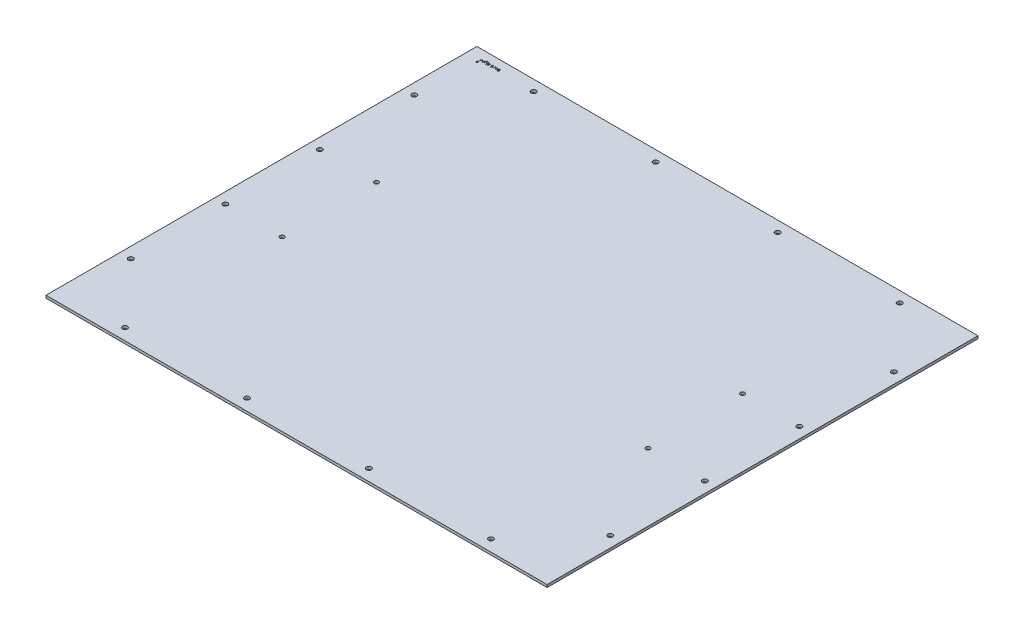
from build123d import *

# Parameters (mm, degrees)
SKETCH1_W                = 584.2
SKETCH1_H                = 502.3866
TOPPLATE_DEPTH           = 3.0734
SKETCH2_R                = 2.8956
FRONT_REARTOPHOLES_DEPTH = 4.0734
LPATTERN1_COUNT          = 4
LPATTERN1_PITCH          = 142.24
SKETCH3_R                = 2.8956
CUT_EXTRUDE2_DEPTH       = 4.0734
LPATTERN2_COUNT          = 4
LPATTERN2_PITCH          = 110.202133333
F_10_CLEARANCE_HOLE1_D   = 5.1054
SKETCH6_W                = 0.284935897
SKETCH6_H                = 2.320192308
CUT_EXTRUDE3_DEPTH       = 1.27


with BuildPart() as part:
    # Sketch1 → TopPlate (new body)
    with BuildSketch(Plane(origin=(0, 0, 0), x_dir=(1, 0, 0), z_dir=(0, 1, 0))):
        Rectangle(SKETCH1_W, SKETCH1_H)
    extrude(amount=TOPPLATE_DEPTH)

    # Sketch2 → Front/RearTopHoles (cut, through all)
    with BuildSketch(Plane(origin=(0, 3.0734, 0), x_dir=(1, 0, 0), z_dir=(0, 1, 0))):
        with Locations((-213.36, 238.5949)):
            Circle(SKETCH2_R)
        with Locations((-213.36, -237.8583)):
            Circle(SKETCH2_R)
    front_reartopholes = extrude(amount=-FRONT_REARTOPHOLES_DEPTH, mode=Mode.SUBTRACT)

    # LPattern1: Front/RearTopHoles ×4
    with Locations(*[(i * LPATTERN1_PITCH, 0, 0) for i in range(1, LPATTERN1_COUNT)]):
        add(front_reartopholes, mode=Mode.SUBTRACT)

    # Sketch3 → Cut-Extrude2 (cut, through all)
    with BuildSketch(Plane(origin=(0, 3.0734, 0), x_dir=(1, 0, 0), z_dir=(0, 1, 0))):
        with Locations((-279.5016, 165.6715)):
            Circle(SKETCH3_R)
        with Locations((279.5016, 165.6715)):
            Circle(SKETCH3_R)
    cut_extrude2 = extrude(amount=-CUT_EXTRUDE2_DEPTH, mode=Mode.SUBTRACT)

    # LPattern2: Cut-Extrude2 ×4
    with Locations(*[(0, 0, i * LPATTERN2_PITCH) for i in range(1, LPATTERN2_COUNT)]):
        add(cut_extrude2, mode=Mode.SUBTRACT)

    # #10 Clearance Hole1 (through all)
    with Locations(Plane(origin=(0, 3.0734, 0), x_dir=(1, 0, 0), z_dir=(0, 1, 0))):
        with Locations((-213.36, 55.469366667), (-213.36, -54.732766667), (213.36, -54.732766667), (213.36, 55.469366667)):
            Hole(F_10_CLEARANCE_HOLE1_D / 2)

    # Sketch6 → Cut-Extrude3 (cut)
    with BuildSketch(Plane(origin=(0, 3.0734, 0), x_dir=(1, 0, 0), z_dir=(0, 1, 0))):
        Polygon((-276.606, 234.501752747), (-275.59, 235.771752747), (-276.098, 235.771752747), (-276.098, 237.041752747), (-277.114, 237.041752747), (-277.114, 235.771752747), (-277.622, 235.771752747), align=None)
        Polygon((-275.751192308, 238.234089744), (-276.036128205, 238.234089744), (-276.036128205, 239.170307692), (-276.443179487, 239.170307692), (-276.443179487, 239.45524359), (-276.036128205, 239.45524359), (-276.036128205, 241.4905), (-275.751192308, 241.4905), (-275.751192308, 239.45524359), (-275.344141026, 239.45524359), (-275.344141026, 239.170307692), (-275.751192308, 239.170307692), align=None)
        with BuildLine():
            Line((-272.779717949, 238.234089744), (-273.064653846, 238.234089744))
            Line((-273.064653846, 238.234089744), (-273.064653846, 239.608523838))
            add(Edge.make_bspline(
                [(-273.064653846, 239.608523838), (-273.095288957, 239.570346385), (-273.154842441, 239.496130876), (-273.254397625, 239.398250964), (-273.358134855, 239.314880555), (-273.466934482, 239.246800624), (-273.580334104, 239.193987133), (-273.698612372, 239.157038512), (-273.821467744, 239.133998173), (-273.905156662, 239.131078123), (-273.947446314, 239.129602564)],
                knots=[0, 0, 0, 0, 0.000146744, 0.000285264, 0.000417869, 0.000545289, 0.000669358, 0.000792061, 0.000916189, 0.001042986, 0.001042986, 0.001042986, 0.001042986], degree=3))
            add(Edge.make_bspline(
                [(-273.947446314, 239.129602564), (-273.99040245, 239.131096275), (-274.074520115, 239.134021292), (-274.196554238, 239.159794398), (-274.311327974, 239.200580783), (-274.417308171, 239.257903038), (-274.51285836, 239.329075871), (-274.595732695, 239.412549345), (-274.665255082, 239.507224035), (-274.71177071, 239.5954719), (-274.742257141, 239.673949775), (-274.761528408, 239.7412988), (-274.777876587, 239.81633759), (-274.792117817, 239.899037579), (-274.801609985, 239.989792673), (-274.809234113, 240.088194368), (-274.814655629, 240.194236739), (-274.814865725, 240.267642968), (-274.814974359, 240.305599159)],
                knots=[0, 0, 0, 0, 0.000128741, 0.000252104, 0.000372411, 0.000493068, 0.000612131, 0.000728612, 0.000844628, 0.000963265, 0.001026692, 0.001096933, 0.001173163, 0.001257021, 0.001348539, 0.001446782, 0.001553119, 0.001666973, 0.001666973, 0.001666973, 0.001666973], degree=3))
            Line((-274.814974359, 240.305599159), (-274.814974359, 241.4905))
            Line((-274.814974359, 241.4905), (-274.530038462, 241.4905))
            Line((-274.530038462, 241.4905), (-274.530038462, 240.39909375))
            add(Edge.make_bspline(
                [(-274.530038462, 240.39909375), (-274.52986652, 240.367504573), (-274.529537624, 240.307079855), (-274.528437062, 240.220569698), (-274.526036138, 240.14231524), (-274.522012923, 240.072154038), (-274.517964628, 240.010181175), (-274.512225203, 239.956295425), (-274.505597355, 239.91083483), (-274.499638148, 239.883471229), (-274.496965545, 239.871199119)],
                knots=[0, 0, 0, 0, 9.4769e-05, 0.000181277, 0.000259548, 0.000329614, 0.000392103, 0.000445834, 0.000492158, 0.000529829, 0.000529829, 0.000529829, 0.000529829], degree=3))
            add(Edge.make_bspline(
                [(-274.496965545, 239.871199119), (-274.486650236, 239.835164317), (-274.466871505, 239.766070641), (-274.41998111, 239.672384203), (-274.362778171, 239.591782233), (-274.291875741, 239.526554072), (-274.209629226, 239.475158281), (-274.115257802, 239.4401423), (-274.009967367, 239.417812227), (-273.935909524, 239.415662226), (-273.897200921, 239.414538462)],
                knots=[0, 0, 0, 0, 0.000112235, 0.000215201, 0.000312651, 0.000407163, 0.00050229, 0.000601745, 0.000707647, 0.000823614, 0.000823614, 0.000823614, 0.000823614], degree=3))
            add(Edge.make_bspline(
                [(-273.897200921, 239.414538462), (-273.874277404, 239.414963891), (-273.828912354, 239.415805804), (-273.761678637, 239.424472437), (-273.696256264, 239.438160215), (-273.632820828, 239.458378282), (-273.571242928, 239.482959628), (-273.511272258, 239.513125858), (-273.453729552, 239.549600076), (-273.397872102, 239.590651447), (-273.345874308, 239.636065114), (-273.29749967, 239.684006601), (-273.254375428, 239.735055575), (-273.215306109, 239.788395801), (-273.181580081, 239.844758182), (-273.152140503, 239.903599394), (-273.127161691, 239.964996766), (-273.114749535, 240.007609858), (-273.108539062, 240.02893149)],
                knots=[0, 0, 0, 0, 6.8737e-05, 0.000136029, 0.000203016, 0.000268997, 0.00033549, 0.000401764, 0.000470059, 0.000539641, 0.000609525, 0.000676984, 0.000743763, 0.00080979, 0.000875126, 0.000940547, 0.00100704, 0.001073628, 0.001073628, 0.001073628, 0.001073628], degree=3))
            add(Edge.make_bspline(
                [(-273.108539062, 240.02893149), (-273.104965439, 240.044371924), (-273.097178074, 240.078018531), (-273.08872819, 240.133512382), (-273.081164617, 240.197997876), (-273.074770576, 240.271377207), (-273.070848919, 240.353919262), (-273.066623229, 240.445060775), (-273.06505023, 240.545372651), (-273.064789923, 240.615127861), (-273.064653846, 240.651592748)],
                knots=[0, 0, 0, 0, 4.7531e-05, 0.000103577, 0.000168266, 0.000242318, 0.000324485, 0.000416151, 0.000516024, 0.000625421, 0.000625421, 0.000625421, 0.000625421], degree=3))
            Line((-273.064653846, 240.651592748), (-273.064653846, 241.4905))
            Line((-273.064653846, 241.4905), (-272.779717949, 241.4905))
            Line((-272.779717949, 241.4905), (-272.779717949, 238.234089744))
        make_face()
        with BuildLine():
            Line((-271.8435, 239.170307692), (-272.128435897, 239.170307692))
            Line((-272.128435897, 239.170307692), (-272.128435897, 241.011578726))
            add(Edge.make_bspline(
                [(-272.128435897, 241.011578726), (-272.12818458, 241.050801401), (-272.127699478, 241.126510612), (-272.124206096, 241.235983051), (-272.116839482, 241.337098715), (-272.108485893, 241.430318764), (-272.096469229, 241.515211106), (-272.081794953, 241.592029056), (-272.065252586, 241.660846331), (-272.050719961, 241.703232436), (-272.043845553, 241.723282452)],
                knots=[0, 0, 0, 0, 0.00011767, 0.000227132, 0.0003285, 0.000421785, 0.000507864, 0.000585575, 0.000656379, 0.000719936, 0.000719936, 0.000719936, 0.000719936], degree=3))
            add(Edge.make_bspline(
                [(-272.043845553, 241.723282452), (-272.033696249, 241.749345441), (-272.013701098, 241.800692153), (-271.976235724, 241.873463997), (-271.934344658, 241.942040388), (-271.886342636, 242.0056571), (-271.83338637, 242.065242755), (-271.774817784, 242.119937838), (-271.710779765, 242.169673775), (-271.641845981, 242.21492206), (-271.568506921, 242.255357007), (-271.491164154, 242.290601015), (-271.410011572, 242.319746935), (-271.325408027, 242.343779291), (-271.237316212, 242.363153814), (-271.145454597, 242.376084095), (-271.050130374, 242.384789849), (-270.985320336, 242.385601191), (-270.952439303, 242.386012821)],
                knots=[0, 0, 0, 0, 8.3858e-05, 0.000165209, 0.000245167, 0.00032467, 0.00040395, 0.000484048, 0.000564709, 0.000646913, 0.000731175, 0.000815711, 0.00090162, 0.000989596, 0.001079416, 0.001171971, 0.001267732, 0.001366347, 0.001366347, 0.001366347, 0.001366347], degree=3))
            add(Edge.make_bspline(
                [(-270.952439303, 242.386012821), (-270.90447824, 242.385140136), (-270.810822493, 242.383436007), (-270.674004238, 242.367091364), (-270.544657436, 242.340891053), (-270.423652145, 242.303172693), (-270.311909172, 242.256728639), (-270.209791061, 242.203946576), (-270.119001866, 242.142785218), (-270.037232791, 242.0734154), (-269.963448258, 241.990890778), (-269.894025893, 241.893648398), (-269.827205256, 241.780194164), (-269.788045081, 241.696925164), (-269.767538462, 241.653320513)],
                knots=[0, 0, 0, 0, 0.00014383, 0.000280863, 0.000412709, 0.000539245, 0.000660431, 0.000775365, 0.0008835, 0.000988151, 0.001096222, 0.001214668, 0.001346108, 0.001490606, 0.001490606, 0.001490606, 0.001490606], degree=3))
            Line((-269.767538462, 241.653320513), (-270.052474359, 241.653320513))
            add(Edge.make_bspline(
                [(-270.052474359, 241.653320513), (-270.075401181, 241.689690608), (-270.120220295, 241.760789664), (-270.203755387, 241.852938639), (-270.295975421, 241.930967298), (-270.398837112, 241.994278604), (-270.513057864, 242.043017864), (-270.639376644, 242.076871614), (-270.778139147, 242.097352938), (-270.874770736, 242.099801738), (-270.925090545, 242.101076923)],
                knots=[0, 0, 0, 0, 0.000128773, 0.000251735, 0.000371362, 0.000490154, 0.000612668, 0.000742586, 0.000881465, 0.001032363, 0.001032363, 0.001032363, 0.001032363], degree=3))
            add(Edge.make_bspline(
                [(-270.925090545, 242.101076923), (-270.974775422, 242.099790902), (-271.070562891, 242.097311581), (-271.20845158, 242.076771655), (-271.334609236, 242.043101585), (-271.447422374, 241.994555846), (-271.545815237, 241.935771451), (-271.631421221, 241.871385539), (-271.700260177, 241.797651596), (-271.746752525, 241.729856808), (-271.77562316, 241.669412722), (-271.794025821, 241.61738927), (-271.808867227, 241.558750354), (-271.821607536, 241.493356365), (-271.831702776, 241.421182106), (-271.838326273, 241.341981473), (-271.843027303, 241.25629015), (-271.843338791, 241.196878996), (-271.8435, 241.16613101)],
                knots=[0, 0, 0, 0, 0.000148992, 0.000287243, 0.00041716, 0.000539674, 0.000654314, 0.000760413, 0.000859854, 0.000955639, 0.001005707, 0.001060427, 0.001120899, 0.001187008, 0.001260225, 0.0013394, 0.001425378, 0.001517609, 0.001517609, 0.001517609, 0.001517609], degree=3))
            Line((-271.8435, 241.16613101), (-271.8435, 241.045923678))
            add(Edge.make_bspline(
                [(-271.8435, 241.045923678), (-271.814569532, 241.080328344), (-271.757217475, 241.148532507), (-271.658438924, 241.238064123), (-271.549866918, 241.314241385), (-271.433036156, 241.377605615), (-271.309687811, 241.427808387), (-271.182002694, 241.464184676), (-271.050339266, 241.486747874), (-270.961221094, 241.489240421), (-270.916186298, 241.4905)],
                knots=[0, 0, 0, 0, 0.000134741, 0.000267112, 0.000398573, 0.000531766, 0.000664992, 0.000797261, 0.000929425, 0.001064443, 0.001064443, 0.001064443, 0.001064443], degree=3))
            add(Edge.make_bspline(
                [(-270.916186298, 241.4905), (-270.889674897, 241.489940414), (-270.836985562, 241.488828282), (-270.758487063, 241.48206311), (-270.681501426, 241.468889036), (-270.605538248, 241.452019574), (-270.531128225, 241.429406531), (-270.457379793, 241.402866048), (-270.38536394, 241.370267322), (-270.314713264, 241.333565607), (-270.247089783, 241.292328762), (-270.182706743, 241.247775307), (-270.121957835, 241.200001608), (-270.065414273, 241.148567792), (-270.013123282, 241.093557625), (-269.964495723, 241.035490185), (-269.919971489, 240.973908019), (-269.880127551, 240.908787337), (-269.843726172, 240.841715809), (-269.812559987, 240.772372177), (-269.786688047, 240.701195133), (-269.763886912, 240.6290745), (-269.747740892, 240.55469513), (-269.735394701, 240.478938573), (-269.728467691, 240.401342651), (-269.727380427, 240.34907289), (-269.726833333, 240.322771635)],
                knots=[0, 0, 0, 0, 7.9543e-05, 0.000158085, 0.000236088, 0.000313697, 0.00039137, 0.000469237, 0.000548668, 0.000628323, 0.000707949, 0.000786107, 0.000863089, 0.000939628, 0.001015205, 0.001090612, 0.001166693, 0.001242943, 0.00131949, 0.001395499, 0.001470759, 0.001546605, 0.001622214, 0.001698859, 0.001776768, 0.001855675, 0.001855675, 0.001855675, 0.001855675], degree=3))
            add(Edge.make_bspline(
                [(-269.726833333, 240.322771635), (-269.727303962, 240.296461557), (-269.728243396, 240.243943305), (-269.736368104, 240.166040304), (-269.747932416, 240.089171622), (-269.766331604, 240.014171274), (-269.788163501, 239.939956522), (-269.816478574, 239.867735626), (-269.849101148, 239.796552813), (-269.886387195, 239.72703231), (-269.928124933, 239.659813714), (-269.974066934, 239.59627373), (-270.023252779, 239.535883841), (-270.076672319, 239.479418604), (-270.134009781, 239.426454791), (-270.195431838, 239.377457165), (-270.260255323, 239.331540083), (-270.328702263, 239.289711312), (-270.399710776, 239.252715774), (-270.471478379, 239.218958689), (-270.544955332, 239.192167008), (-270.618771855, 239.168560344), (-270.694227919, 239.151836987), (-270.77039834, 239.138935382), (-270.84754389, 239.131075242), (-270.899208302, 239.13009409), (-270.925090545, 239.129602564)],
                knots=[0, 0, 0, 0, 7.8907e-05, 0.000157509, 0.000234782, 0.000311916, 0.000388979, 0.000466698, 0.000544391, 0.000623781, 0.0007032, 0.000781572, 0.000858855, 0.000936691, 0.001014559, 0.00109283, 0.001172238, 0.001252739, 0.001333252, 0.001412367, 0.001490455, 0.001567704, 0.001644694, 0.001722069, 0.001799404, 0.00187704, 0.00187704, 0.00187704, 0.00187704], degree=3))
            add(Edge.make_bspline(
                [(-270.925090545, 239.129602564), (-270.967775914, 239.130814084), (-271.051856641, 239.13320051), (-271.175840296, 239.152506785), (-271.295608346, 239.182597742), (-271.411774325, 239.22634062), (-271.525047299, 239.285536822), (-271.634745544, 239.364511684), (-271.742747017, 239.461705246), (-271.809060471, 239.536988825), (-271.8435, 239.576086939)],
                knots=[0, 0, 0, 0, 0.000127998, 0.000252127, 0.000375534, 0.000497914, 0.000623661, 0.000757781, 0.000902347, 0.00105855, 0.00105855, 0.00105855, 0.00105855], degree=3))
            Line((-271.8435, 239.576086939), (-271.8435, 239.170307692))
        make_face()
        with BuildLine():
            add(Edge.make_bspline(
                [(-270.947987179, 239.414538462), (-270.906324102, 239.415959755), (-270.823840042, 239.418773616), (-270.702890132, 239.442632797), (-270.586393338, 239.480395931), (-270.475504221, 239.532961353), (-270.372755286, 239.599381768), (-270.28086539, 239.678451332), (-270.20059951, 239.768785992), (-270.133524905, 239.870078155), (-270.079438352, 239.979026265), (-270.040630891, 240.093669245), (-270.015842236, 240.212527338), (-270.013135685, 240.293393231), (-270.011769231, 240.334219952)],
                knots=[0, 0, 0, 0, 0.000124893, 0.000247261, 0.000368342, 0.000491529, 0.000614314, 0.00073428, 0.000854125, 0.000975665, 0.001097689, 0.001217965, 0.001337959, 0.001460312, 0.001460312, 0.001460312, 0.001460312], degree=3))
            add(Edge.make_bspline(
                [(-270.011769231, 240.334219952), (-270.01242994, 240.365001466), (-270.013729363, 240.425539702), (-270.026145185, 240.514394939), (-270.046434926, 240.59916618), (-270.07454538, 240.679716085), (-270.110232087, 240.756363269), (-270.15530564, 240.828211546), (-270.207481931, 240.896554451), (-270.26728107, 240.959917012), (-270.333086668, 241.017707641), (-270.404413334, 241.068222957), (-270.480874622, 241.110106127), (-270.561247668, 241.145767369), (-270.647234371, 241.172001358), (-270.737545276, 241.191983431), (-270.832786176, 241.203424212), (-270.897712186, 241.204841499), (-270.930814704, 241.205564103)],
                knots=[0, 0, 0, 0, 9.2301e-05, 0.00018153, 0.000268534, 0.000353418, 0.000437066, 0.000521609, 0.000607348, 0.000694638, 0.000782531, 0.000869702, 0.00095625, 0.00104369, 0.001133005, 0.001225446, 0.001320902, 0.001420194, 0.001420194, 0.001420194, 0.001420194], degree=3))
            add(Edge.make_bspline(
                [(-270.930814704, 241.205564103), (-270.964346113, 241.204867772), (-271.029916429, 241.203506104), (-271.125684347, 241.191800786), (-271.216428342, 241.172912283), (-271.302065155, 241.146094381), (-271.382918321, 241.111875417), (-271.458078847, 241.068571294), (-271.529161001, 241.019255701), (-271.593885242, 240.961729277), (-271.652440982, 240.898343518), (-271.703365192, 240.829323404), (-271.74710102, 240.756000943), (-271.781910316, 240.677441311), (-271.810623886, 240.59468262), (-271.828726051, 240.506329395), (-271.841708964, 240.413682037), (-271.842893913, 240.350169433), (-271.8435, 240.317683494)],
                knots=[0, 0, 0, 0, 0.000100563, 0.00019665, 0.000288958, 0.000378273, 0.000465461, 0.000551765, 0.00063805, 0.000724567, 0.000810991, 0.000896473, 0.000981445, 0.00106656, 0.00115385, 0.00124367, 0.001336681, 0.001434067, 0.001434067, 0.001434067, 0.001434067], degree=3))
            add(Edge.make_bspline(
                [(-271.8435, 240.317683494), (-271.84228264, 240.275395339), (-271.839904347, 240.192779144), (-271.817531089, 240.072382543), (-271.781237896, 239.959063042), (-271.730868708, 239.853110797), (-271.667460113, 239.756000859), (-271.590338308, 239.670194953), (-271.5029189, 239.593316589), (-271.403052269, 239.530133743), (-271.296014202, 239.478434889), (-271.183571689, 239.441407847), (-271.066954016, 239.419102752), (-270.98794091, 239.416071329), (-270.947987179, 239.414538462)],
                knots=[0, 0, 0, 0, 0.000126761, 0.000247646, 0.000365914, 0.00048284, 0.00059856, 0.000712542, 0.000827958, 0.00094669, 0.001065886, 0.001183746, 0.001300879, 0.001420694, 0.001420694, 0.001420694, 0.001420694], degree=3))
        make_face(mode=Mode.SUBTRACT)
        with BuildLine():
            add(Edge.make_bspline(
                [(-269.013221554, 238.193384615), (-269.03090001, 238.194208369), (-269.065517822, 238.195821435), (-269.115627934, 238.209524526), (-269.16121077, 238.233106406), (-269.202245007, 238.263716262), (-269.236260502, 238.301194976), (-269.260651423, 238.343779081), (-269.276222513, 238.390138508), (-269.278113917, 238.422440769), (-269.279076923, 238.43888742)],
                knots=[0, 0, 0, 0, 5.2977e-05, 0.000103739, 0.000154369, 0.000206141, 0.000256583, 0.000305021, 0.000352489, 0.000401726, 0.000401726, 0.000401726, 0.000401726], degree=3))
            add(Edge.make_bspline(
                [(-269.279076923, 238.43888742), (-269.278092374, 238.454907167), (-269.276146037, 238.486576312), (-269.260662934, 238.532131925), (-269.236056013, 238.574123055), (-269.202267647, 238.611528496), (-269.161204791, 238.642120668), (-269.115629515, 238.66570722), (-269.065517406, 238.679409077), (-269.03089987, 238.681022314), (-269.013221554, 238.681846154)],
                knots=[0, 0, 0, 0, 4.7972e-05, 9.4835e-05, 0.000142722, 0.000193165, 0.000244937, 0.000295567, 0.000346329, 0.000399306, 0.000399306, 0.000399306, 0.000399306], degree=3))
            add(Edge.make_bspline(
                [(-269.013221554, 238.681846154), (-268.995746279, 238.681048773), (-268.961732938, 238.679496774), (-268.912544204, 238.665543289), (-268.867694811, 238.642171959), (-268.827331639, 238.611105142), (-268.79287337, 238.574371777), (-268.768357242, 238.532100207), (-268.752832742, 238.486584388), (-268.750891984, 238.45490988), (-268.749910256, 238.43888742)],
                knots=[0, 0, 0, 0, 5.2343e-05, 0.000101879, 0.000151943, 0.000203209, 0.000254078, 0.000301966, 0.000348828, 0.0003968, 0.0003968, 0.0003968, 0.0003968], degree=3))
            add(Edge.make_bspline(
                [(-268.749910256, 238.43888742), (-268.750870335, 238.422437953), (-268.752755991, 238.390130162), (-268.768369291, 238.343811342), (-268.792666358, 238.300944133), (-268.827353903, 238.264139309), (-268.867688983, 238.233055228), (-268.912545722, 238.209688412), (-268.961732535, 238.195733747), (-268.995746142, 238.194181913), (-269.013221554, 238.193384615)],
                knots=[0, 0, 0, 0, 4.9237e-05, 9.6705e-05, 0.000145142, 0.000196012, 0.000247277, 0.000297341, 0.000346877, 0.00039922, 0.00039922, 0.00039922, 0.00039922], degree=3))
        make_face()
        with Locations((-269.01449359, 240.330403846)):
            Rectangle(SKETCH6_W, SKETCH6_H)
        with BuildLine():
            Line((-266.307602564, 238.3155), (-266.942984175, 238.3155))
            add(Edge.make_bspline(
                [(-266.942984175, 238.3155), (-266.985385056, 238.315641139), (-267.066799444, 238.315912141), (-267.183433768, 238.317423226), (-267.289412634, 238.321754248), (-267.384680631, 238.32548132), (-267.469236011, 238.332277582), (-267.543338053, 238.338773311), (-267.606645465, 238.347276561), (-267.644968487, 238.355173623), (-267.662320112, 238.358749199)],
                knots=[0, 0, 0, 0, 0.000127205, 0.000244248, 0.000349896, 0.000445402, 0.000530231, 0.00060434, 0.000668562, 0.000721699, 0.000721699, 0.000721699, 0.000721699], degree=3))
            add(Edge.make_bspline(
                [(-267.662320112, 238.358749199), (-267.685549369, 238.364487843), (-267.731512341, 238.375842711), (-267.797682798, 238.399854569), (-267.860763154, 238.427596928), (-267.920522408, 238.460430236), (-267.9769449, 238.497800062), (-268.030024945, 238.539856633), (-268.079050844, 238.586960289), (-268.125766864, 238.637159811), (-268.166558873, 238.692640823), (-268.203282502, 238.750587813), (-268.234110731, 238.812116403), (-268.258369106, 238.876916258), (-268.278705613, 238.944351724), (-268.292373644, 239.015089154), (-268.300886333, 239.088898406), (-268.301727387, 239.139119001), (-268.302153846, 239.164583534)],
                knots=[0, 0, 0, 0, 7.1738e-05, 0.000141945, 0.000210849, 0.000278309, 0.000346223, 0.000413668, 0.000481152, 0.000550033, 0.000619105, 0.000687399, 0.000755663, 0.000825118, 0.000894749, 0.00096672, 0.00104096, 0.001117325, 0.001117325, 0.001117325, 0.001117325], degree=3))
            add(Edge.make_bspline(
                [(-268.302153846, 239.164583534), (-268.30082129, 239.206888284), (-268.298221127, 239.28943581), (-268.273977157, 239.409233216), (-268.234267366, 239.520986009), (-268.179539017, 239.624538669), (-268.109876865, 239.717927231), (-268.026158798, 239.799676017), (-267.928812361, 239.868716591), (-267.837763743, 239.91608451), (-267.757298009, 239.946563059), (-267.690859166, 239.968115533), (-267.618330587, 239.984486719), (-267.540752805, 239.99936584), (-267.457526603, 240.010719804), (-267.368819576, 240.018783277), (-267.274409863, 240.023968151), (-267.209694508, 240.024725683), (-267.176402644, 240.025115385)],
                knots=[0, 0, 0, 0, 0.000126797, 0.000247415, 0.000364897, 0.000481551, 0.000597433, 0.000713022, 0.000831097, 0.00095427, 0.001019706, 0.001089102, 0.001163613, 0.001242574, 0.001326045, 0.001415471, 0.001509739, 0.001609612, 0.001609612, 0.001609612, 0.001609612], degree=3))
            Line((-267.176402644, 240.025115385), (-268.342858974, 241.4905))
            Line((-268.342858974, 241.4905), (-267.990505208, 241.4905))
            Line((-267.990505208, 241.4905), (-266.824048878, 240.025115385))
            Line((-266.824048878, 240.025115385), (-266.592538462, 240.025115385))
            Line((-266.592538462, 240.025115385), (-266.592538462, 241.4905))
            Line((-266.592538462, 241.4905), (-266.307602564, 241.4905))
            Line((-266.307602564, 241.4905), (-266.307602564, 238.3155))
        make_face()
        with BuildLine():
            Line((-266.592538462, 238.641141026), (-266.592538462, 239.699474359))
            Line((-266.592538462, 239.699474359), (-267.173858574, 239.703926482))
            add(Edge.make_bspline(
                [(-267.173858574, 239.703926482), (-267.201000327, 239.703938497), (-267.253608774, 239.703961784), (-267.329718617, 239.700338765), (-267.400584876, 239.696217644), (-267.465935604, 239.689912535), (-267.525802933, 239.681791581), (-267.58014732, 239.671617517), (-267.629088859, 239.65981444), (-267.685987255, 239.641359418), (-267.750254088, 239.613381499), (-267.818657485, 239.569999305), (-267.878474298, 239.517534935), (-267.928205373, 239.45678401), (-267.968149429, 239.389702433), (-267.995894134, 239.317808361), (-268.014177733, 239.242234554), (-268.016192859, 239.190344063), (-268.017217949, 239.163947516)],
                knots=[0, 0, 0, 0, 8.1413e-05, 0.000157801, 0.000228539, 0.000294357, 0.000354712, 0.000409723, 0.000460165, 0.000505621, 0.000589056, 0.00066969, 0.000747651, 0.000826724, 0.000904279, 0.000980813, 0.001057183, 0.001136257, 0.001136257, 0.001136257, 0.001136257], degree=3))
            add(Edge.make_bspline(
                [(-268.017217949, 239.163947516), (-268.016140955, 239.138409559), (-268.014006748, 239.087802648), (-267.996185248, 239.013882177), (-267.967085562, 238.943593511), (-267.927255561, 238.877903868), (-267.877682853, 238.818716571), (-267.819941812, 238.768229723), (-267.755391215, 238.726286689), (-267.695548611, 238.698612572), (-267.641669192, 238.682329079), (-267.595104151, 238.67050891), (-267.542030906, 238.662230598), (-267.483074123, 238.654616763), (-267.417974809, 238.648169012), (-267.346693292, 238.643889312), (-267.26928054, 238.641331329), (-267.215625838, 238.641205936), (-267.187850962, 238.641141026)],
                knots=[0, 0, 0, 0, 7.6536e-05, 0.000151667, 0.000226669, 0.000304005, 0.000381204, 0.00045737, 0.000533227, 0.000611498, 0.000654145, 0.000701964, 0.0007555, 0.00081514, 0.000880324, 0.000951697, 0.001029333, 0.001112654, 0.001112654, 0.001112654, 0.001112654], degree=3))
            Line((-267.187850962, 238.641141026), (-266.592538462, 238.641141026))
        make_face(mode=Mode.SUBTRACT)
        Polygon((-262.806961538, 238.234089744), (-263.091897436, 238.234089744), (-263.091897436, 240.116701923), (-264.147686699, 239.170307692), (-264.557282051, 239.170307692), (-263.332312099, 240.269346154), (-264.679397436, 241.4905), (-264.270438101, 241.4905), (-263.091897436, 240.421354367), (-263.091897436, 241.4905), (-262.806961538, 241.4905), align=None)
        with BuildLine():
            Line((-262.237089744, 239.673397636), (-261.998583133, 239.821589744))
            add(Edge.make_bspline(
                [(-261.998583133, 239.821589744), (-261.972431786, 239.789085519), (-261.9209573, 239.72510647), (-261.831547298, 239.64258677), (-261.736214838, 239.571423144), (-261.633162437, 239.514204555), (-261.523292996, 239.469036372), (-261.406380165, 239.437645079), (-261.282460017, 239.4179139), (-261.197489687, 239.415682043), (-261.153951723, 239.414538462)],
                knots=[0, 0, 0, 0, 0.000125005, 0.00024605, 0.000363844, 0.000481156, 0.000598675, 0.000719332, 0.000843558, 0.000974097, 0.000974097, 0.000974097, 0.000974097], degree=3))
            add(Edge.make_bspline(
                [(-261.153951723, 239.414538462), (-261.11915471, 239.415497226), (-261.05062294, 239.417385488), (-260.950014629, 239.429187036), (-260.854184043, 239.450636711), (-260.762518032, 239.478884263), (-260.675714028, 239.516797438), (-260.593528846, 239.56265657), (-260.515687598, 239.616657062), (-260.443426861, 239.678409888), (-260.377572077, 239.746236817), (-260.319329021, 239.817864949), (-260.270717442, 239.89379579), (-260.230195809, 239.972588209), (-260.19970807, 240.055597704), (-260.177288136, 240.141815831), (-260.163622283, 240.231809924), (-260.16196647, 240.293043705), (-260.161128205, 240.32404367)],
                knots=[0, 0, 0, 0, 0.000104402, 0.000205617, 0.000303301, 0.000398648, 0.000492936, 0.000586896, 0.000680581, 0.000776679, 0.000871582, 0.000963859, 0.001053128, 0.00114159, 0.001229132, 0.001317833, 0.001408501, 0.001501466, 0.001501466, 0.001501466, 0.001501466], degree=3))
            add(Edge.make_bspline(
                [(-260.161128205, 240.32404367), (-260.162763055, 240.364651715), (-260.166019092, 240.445528448), (-260.190893213, 240.564678621), (-260.232248688, 240.679882941), (-260.289215405, 240.789796934), (-260.360354232, 240.891832705), (-260.44332621, 240.984103519), (-260.540014864, 241.062753641), (-260.647571015, 241.128578406), (-260.764055698, 241.181707496), (-260.888544673, 241.21919749), (-261.019978048, 241.241952777), (-261.109974323, 241.244811622), (-261.155859776, 241.246269231)],
                knots=[0, 0, 0, 0, 0.00012176, 0.000242503, 0.000363409, 0.000488003, 0.000612742, 0.000735658, 0.000859034, 0.000985243, 0.001113046, 0.001242014, 0.001374284, 0.001511876, 0.001511876, 0.001511876, 0.001511876], degree=3))
            add(Edge.make_bspline(
                [(-261.155859776, 241.246269231), (-261.19791055, 241.245090401), (-261.280551481, 241.242773688), (-261.401353232, 241.223243843), (-261.516360723, 241.191272832), (-261.625569865, 241.146688893), (-261.728781101, 241.08906036), (-261.825327567, 241.017977398), (-261.917130368, 240.935484911), (-261.971102625, 240.871696466), (-261.998583133, 240.839217949)],
                knots=[0, 0, 0, 0, 0.000126092, 0.000247804, 0.000366009, 0.000483528, 0.00060084, 0.00071966, 0.000842576, 0.00097008, 0.00097008, 0.00097008, 0.00097008], degree=3))
            Line((-261.998583133, 240.839217949), (-262.237089744, 240.995678285))
            add(Edge.make_bspline(
                [(-262.237089744, 240.995678285), (-262.22294935, 241.016443275), (-262.194715496, 241.057904333), (-262.147520811, 241.116366882), (-262.096605305, 241.171077731), (-262.042208265, 241.222020547), (-261.985020044, 241.270088919), (-261.923552056, 241.31392061), (-261.858850735, 241.354624767), (-261.79061923, 241.39151183), (-261.719529516, 241.424596379), (-261.645579424, 241.453227945), (-261.569103011, 241.477435869), (-261.490272124, 241.497024001), (-261.408962364, 241.51252054), (-261.325235651, 241.522827022), (-261.23910765, 241.530513396), (-261.180894425, 241.530972552), (-261.151407652, 241.531205128)],
                knots=[0, 0, 0, 0, 7.5343e-05, 0.000150436, 0.000225141, 0.000299381, 0.000373893, 0.000449085, 0.000525672, 0.000603081, 0.000681618, 0.000760753, 0.00084081, 0.000922104, 0.001004308, 0.001088955, 0.001175102, 0.001263529, 0.001263529, 0.001263529, 0.001263529], degree=3))
            add(Edge.make_bspline(
                [(-261.151407652, 241.531205128), (-261.106404082, 241.530395267), (-261.018196759, 241.528807933), (-260.889081604, 241.511402053), (-260.765727949, 241.485064538), (-260.647918964, 241.447583677), (-260.53637509, 241.398085816), (-260.430166968, 241.339008648), (-260.330393407, 241.268398501), (-260.237697855, 241.187937859), (-260.152958405, 241.100595831), (-260.079112913, 241.006944842), (-260.01687055, 240.908730383), (-259.964223238, 240.806358861), (-259.92515426, 240.698482947), (-259.897132464, 240.586157427), (-259.879334391, 240.469410107), (-259.87724936, 240.389829527), (-259.876192308, 240.349484375)],
                knots=[0, 0, 0, 0, 0.000134932, 0.000264467, 0.000390091, 0.000512988, 0.000634589, 0.000755608, 0.000877012, 0.001000567, 0.001123364, 0.001241569, 0.001357666, 0.001471727, 0.001586219, 0.001700986, 0.001818637, 0.001939616, 0.001939616, 0.001939616, 0.001939616], degree=3))
            add(Edge.make_bspline(
                [(-259.876192308, 240.349484375), (-259.876616711, 240.322112603), (-259.877460919, 240.267665631), (-259.886233146, 240.186744914), (-259.899371896, 240.107257421), (-259.918024614, 240.029317233), (-259.941430729, 239.952688584), (-259.97084772, 239.877780713), (-260.005273958, 239.804157768), (-260.045326358, 239.732726257), (-260.089506786, 239.663918739), (-260.137515984, 239.598126973), (-260.190179444, 239.537035988), (-260.246383055, 239.47911684), (-260.306978311, 239.426098771), (-260.370836343, 239.375691211), (-260.439532977, 239.330505726), (-260.511317386, 239.288311587), (-260.586282312, 239.250807959), (-260.663900138, 239.218479406), (-260.743723291, 239.190855675), (-260.825874034, 239.168985141), (-260.909808557, 239.150645132), (-260.996187896, 239.139108206), (-261.084681702, 239.130956379), (-261.144603951, 239.130057588), (-261.174940304, 239.129602564)],
                knots=[0, 0, 0, 0, 8.2086e-05, 0.000163282, 0.000243898, 0.000323655, 0.000403522, 0.000484073, 0.000564878, 0.000647163, 0.000729553, 0.000810077, 0.000891273, 0.000971331, 0.001051984, 0.001132646, 0.001215201, 0.001298432, 0.00138234, 0.001466442, 0.001550516, 0.001635529, 0.001721351, 0.00180806, 0.001896795, 0.001987781, 0.001987781, 0.001987781, 0.001987781], degree=3))
            add(Edge.make_bspline(
                [(-261.174940304, 239.129602564), (-261.212931699, 239.130438542), (-261.288724589, 239.13210632), (-261.401154236, 239.146152253), (-261.511938734, 239.167304478), (-261.619083218, 239.198730953), (-261.721293574, 239.236410511), (-261.816536779, 239.279793754), (-261.904117817, 239.327904329), (-261.984011498, 239.382383458), (-262.056356211, 239.444131695), (-262.123041035, 239.51284437), (-262.18453658, 239.588957878), (-262.21942745, 239.645018758), (-262.237089744, 239.673397636)],
                knots=[0, 0, 0, 0, 0.000113934, 0.000227299, 0.000339435, 0.00045196, 0.000561834, 0.000666003, 0.000765647, 0.000861264, 0.000955568, 0.001050471, 0.001148211, 0.001248412, 0.001248412, 0.001248412, 0.001248412], degree=3))
        make_face()
        with BuildLine():
            Line((-259.306320513, 239.170307692), (-259.306320513, 241.4905))
            Line((-259.306320513, 241.4905), (-259.021384615, 241.4905))
            Line((-259.021384615, 241.4905), (-259.021384615, 241.089172877))
            add(Edge.make_bspline(
                [(-259.021384615, 241.089172877), (-258.989211184, 241.125444428), (-258.926330956, 241.196334081), (-258.822315148, 241.28951684), (-258.711147567, 241.365595977), (-258.59472216, 241.427349561), (-258.472137755, 241.473900581), (-258.344114284, 241.506695198), (-258.210751916, 241.528028562), (-258.119806008, 241.530136773), (-258.073718349, 241.531205128)],
                knots=[0, 0, 0, 0, 0.000145381, 0.000284135, 0.000417684, 0.000548555, 0.000678605, 0.000810037, 0.000944514, 0.001082676, 0.001082676, 0.001082676, 0.001082676], degree=3))
            add(Edge.make_bspline(
                [(-258.073718349, 241.531205128), (-258.032744451, 241.530092818), (-257.95194211, 241.527899293), (-257.83308162, 241.510876549), (-257.718692024, 241.483553572), (-257.608700421, 241.445507403), (-257.503852094, 241.395300873), (-257.403556249, 241.334544037), (-257.307578815, 241.262900995), (-257.217745081, 241.180678804), (-257.134916152, 241.091468267), (-257.062449205, 240.996040068), (-257.001031108, 240.895704913), (-256.950556433, 240.790491001), (-256.911496482, 240.680475243), (-256.884321325, 240.565733113), (-256.867316925, 240.446455535), (-256.865124511, 240.36523005), (-256.864012821, 240.32404367)],
                knots=[0, 0, 0, 0, 0.000122885, 0.000242334, 0.00035942, 0.00047528, 0.000590784, 0.000707496, 0.000826559, 0.000949475, 0.001072351, 0.001191288, 0.001308331, 0.001424682, 0.001540753, 0.001657839, 0.001777919, 0.001901439, 0.001901439, 0.001901439, 0.001901439], degree=3))
            add(Edge.make_bspline(
                [(-256.864012821, 240.32404367), (-256.865149168, 240.283708567), (-256.867395665, 240.203968244), (-256.884139372, 240.086696481), (-256.912274159, 239.973731458), (-256.951832998, 239.865491639), (-257.002334515, 239.761541107), (-257.064808864, 239.662693172), (-257.137249697, 239.56743574), (-257.220963858, 239.478823547), (-257.311603883, 239.397268435), (-257.408118301, 239.325451286), (-257.509303675, 239.264850226), (-257.615362896, 239.215587455), (-257.72554497, 239.176440259), (-257.840686893, 239.149150893), (-257.960265044, 239.133109115), (-258.041444851, 239.130782645), (-258.082622596, 239.129602564)],
                knots=[0, 0, 0, 0, 0.000120979, 0.000239169, 0.000354553, 0.000469642, 0.000584275, 0.000700571, 0.000819893, 0.000942737, 0.001065699, 0.001185272, 0.001303075, 0.001418882, 0.001535553, 0.001653257, 0.001773251, 0.001896771, 0.001896771, 0.001896771, 0.001896771], degree=3))
            add(Edge.make_bspline(
                [(-258.082622596, 239.129602564), (-258.12997627, 239.130901913), (-258.22283459, 239.133449875), (-258.358848333, 239.15483498), (-258.487578136, 239.190629095), (-258.610139, 239.239484373), (-258.724808549, 239.305275047), (-258.832689148, 239.3866802), (-258.932500755, 239.485673357), (-258.991244138, 239.560980474), (-259.021384615, 239.599619591)],
                knots=[0, 0, 0, 0, 0.000142004, 0.000278464, 0.000411785, 0.000542175, 0.000673208, 0.000807155, 0.000946575, 0.001093489, 0.001093489, 0.001093489, 0.001093489], degree=3))
            Line((-259.021384615, 239.599619591), (-259.021384615, 239.170307692))
            Line((-259.021384615, 239.170307692), (-259.306320513, 239.170307692))
        make_face()
        with BuildLine():
            add(Edge.make_bspline(
                [(-258.086438702, 239.414538462), (-258.04478871, 239.416021657), (-257.962578249, 239.418949248), (-257.841875733, 239.441767094), (-257.726431627, 239.479830458), (-257.616433665, 239.531586525), (-257.514918692, 239.59788445), (-257.422687618, 239.676054844), (-257.34224067, 239.767055444), (-257.274220512, 239.868795496), (-257.217751174, 239.977211882), (-257.178782946, 240.091371052), (-257.152900072, 240.208187514), (-257.150269265, 240.287441696), (-257.148948718, 240.327223758)],
                knots=[0, 0, 0, 0, 0.000124893, 0.000246519, 0.000366995, 0.00048876, 0.000610131, 0.000729684, 0.000850427, 0.000973203, 0.001096085, 0.001215967, 0.001334218, 0.001453398, 0.001453398, 0.001453398, 0.001453398], degree=3))
            add(Edge.make_bspline(
                [(-257.148948718, 240.327223758), (-257.150662951, 240.366758356), (-257.154084699, 240.445672588), (-257.177987786, 240.562668067), (-257.219944631, 240.676082438), (-257.275178726, 240.785896362), (-257.344269609, 240.888395285), (-257.424557778, 240.981076163), (-257.517256851, 241.060451551), (-257.619665726, 241.126936862), (-257.728927814, 241.180418954), (-257.843870711, 241.218140042), (-257.962490997, 241.241956807), (-258.04329063, 241.244826921), (-258.083894631, 241.246269231)],
                knots=[0, 0, 0, 0, 0.000118588, 0.000236711, 0.000356419, 0.000480434, 0.000604621, 0.000726318, 0.000847182, 0.000969433, 0.001091748, 0.001211016, 0.001331511, 0.00145323, 0.00145323, 0.00145323, 0.00145323], degree=3))
            add(Edge.make_bspline(
                [(-258.083894631, 241.246269231), (-258.125120445, 241.244768658), (-258.206905966, 241.241791758), (-258.328025838, 241.218816549), (-258.445348786, 241.180280556), (-258.557919348, 241.127805916), (-258.662610199, 241.062750125), (-258.756134585, 240.986250334), (-258.836930659, 240.898643775), (-258.903452911, 240.80045392), (-258.956603291, 240.69399581), (-258.994237792, 240.580288212), (-259.017095663, 240.460006817), (-259.019935197, 240.37757082), (-259.021384615, 240.335491987)],
                knots=[0, 0, 0, 0, 0.000123623, 0.000245249, 0.000368341, 0.000493255, 0.000616967, 0.000737165, 0.00085465, 0.000973197, 0.001091807, 0.001210471, 0.001331472, 0.001457635, 0.001457635, 0.001457635, 0.001457635], degree=3))
            add(Edge.make_bspline(
                [(-259.021384615, 240.335491987), (-259.020514056, 240.303435539), (-259.01880052, 240.240338305), (-259.005710129, 240.14769388), (-258.984886012, 240.059036075), (-258.955546034, 239.974267852), (-258.91699063, 239.893871988), (-258.870538289, 239.81721829), (-258.815236204, 239.745020777), (-258.752767359, 239.677370882), (-258.683618553, 239.615976048), (-258.61008776, 239.561863157), (-258.532359981, 239.516068761), (-258.450489779, 239.479421266), (-258.365107723, 239.449565471), (-258.275395443, 239.429846235), (-258.182257073, 239.416262724), (-258.118714448, 239.415119267), (-258.086438702, 239.414538462)],
                knots=[0, 0, 0, 0, 9.6142e-05, 0.000189237, 0.000280101, 0.000369007, 0.000457768, 0.000547103, 0.000637419, 0.000730134, 0.000822936, 0.000914401, 0.00100363, 0.001093008, 0.001183116, 0.001274455, 0.00136818, 0.00146493, 0.00146493, 0.00146493, 0.00146493], degree=3))
        make_face(mode=Mode.SUBTRACT)
        with BuildLine():
            Line((-254.503115385, 238.3155), (-255.122596554, 238.3155))
            add(Edge.make_bspline(
                [(-255.122596554, 238.3155), (-255.152921438, 238.315656921), (-255.211698609, 238.315961072), (-255.297162604, 238.320787737), (-255.377239396, 238.327204332), (-255.451787482, 238.337967824), (-255.521291934, 238.349128146), (-255.585047137, 238.365508826), (-255.643587118, 238.383601885), (-255.713881653, 238.41144051), (-255.793640435, 238.454674247), (-255.879366202, 238.518793986), (-255.95388427, 238.595668377), (-256.017246716, 238.683272808), (-256.068096426, 238.77964761), (-256.104418548, 238.882719247), (-256.127753263, 238.990753662), (-256.130122924, 239.064821243), (-256.131320513, 239.102253806)],
                knots=[0, 0, 0, 0, 9.0959e-05, 0.000176302, 0.000256745, 0.000331852, 0.000402223, 0.000467782, 0.000529134, 0.000585943, 0.000694367, 0.0008002, 0.000905896, 0.001014288, 0.001123535, 0.001231562, 0.00134133, 0.001453488, 0.001453488, 0.001453488, 0.001453488], degree=3))
            add(Edge.make_bspline(
                [(-256.131320513, 239.102253806), (-256.130342306, 239.137321674), (-256.128420036, 239.206233341), (-256.109641016, 239.306686738), (-256.08129454, 239.402610727), (-256.040388855, 239.493080893), (-255.988230669, 239.577302276), (-255.924772397, 239.653838275), (-255.84952828, 239.721186236), (-255.793034581, 239.758666335), (-255.764338341, 239.777704527)],
                knots=[0, 0, 0, 0, 0.000105099, 0.000206529, 0.000305524, 0.000404587, 0.000503422, 0.000601875, 0.000701862, 0.000805081, 0.000805081, 0.000805081, 0.000805081], degree=3))
            add(Edge.make_bspline(
                [(-255.764338341, 239.777704527), (-255.800409289, 239.791545853), (-255.869421947, 239.818027739), (-255.964515176, 239.86502874), (-256.046472086, 239.915757679), (-256.116348877, 239.970586384), (-256.174900691, 240.031305168), (-256.227060997, 240.096314962), (-256.271327846, 240.167879834), (-256.309097345, 240.244449009), (-256.339016789, 240.325617005), (-256.359785044, 240.410776589), (-256.372956337, 240.49896321), (-256.374678724, 240.558899436), (-256.375551282, 240.589263021)],
                knots=[0, 0, 0, 0, 0.000115862, 0.000221672, 0.000317675, 0.000404589, 0.000487344, 0.000570185, 0.000654188, 0.000739236, 0.000825961, 0.000913116, 0.001001804, 0.001092863, 0.001092863, 0.001092863, 0.001092863], degree=3))
            add(Edge.make_bspline(
                [(-256.375551282, 240.589263021), (-256.374665058, 240.620257203), (-256.372921388, 240.681239126), (-256.360059342, 240.770824877), (-256.338275188, 240.856433729), (-256.30829136, 240.938635531), (-256.269205932, 241.016948851), (-256.221986673, 241.091989144), (-256.165313603, 241.162644303), (-256.101494151, 241.22993962), (-256.030290005, 241.29147828), (-255.951828606, 241.344362582), (-255.86812084, 241.390040927), (-255.778020427, 241.426763754), (-255.682166693, 241.455511011), (-255.580537182, 241.475386817), (-255.473189602, 241.488832925), (-255.399519687, 241.489934879), (-255.361739183, 241.4905)],
                knots=[0, 0, 0, 0, 9.2965e-05, 0.000182912, 0.000270839, 0.000357564, 0.000444886, 0.000532935, 0.000623027, 0.000716149, 0.000810866, 0.000904715, 0.000999484, 0.001096453, 0.001196056, 0.001299211, 0.001406816, 0.001520092, 0.001520092, 0.001520092, 0.001520092], degree=3))
            Line((-255.361739183, 241.4905), (-254.503115385, 241.4905))
            Line((-254.503115385, 241.4905), (-254.503115385, 238.3155))
        make_face()
        with BuildLine():
            Line((-254.788051282, 238.641141026), (-254.788051282, 239.658769231))
            Line((-254.788051282, 239.658769231), (-254.979492588, 239.658769231))
            add(Edge.make_bspline(
                [(-254.979492588, 239.658769231), (-255.007477105, 239.658409462), (-255.061548893, 239.657714317), (-255.140061464, 239.655660292), (-255.212757463, 239.650160798), (-255.279887372, 239.644344164), (-255.34100131, 239.635387778), (-255.396303699, 239.62442756), (-255.446291877, 239.612937825), (-255.503911309, 239.593341292), (-255.569261624, 239.564682831), (-255.638439146, 239.519118136), (-255.700702025, 239.466364071), (-255.752065307, 239.403789506), (-255.794827103, 239.336214635), (-255.82361696, 239.263135549), (-255.843690319, 239.187070575), (-255.845477317, 239.134612234), (-255.846384615, 239.107977965)],
                knots=[0, 0, 0, 0, 8.3964e-05, 0.000162235, 0.000235554, 0.000302638, 0.000364342, 0.000420722, 0.000471782, 0.000518041, 0.000603156, 0.000685012, 0.000765726, 0.000846997, 0.000926956, 0.001004553, 0.001081836, 0.001161544, 0.001161544, 0.001161544, 0.001161544], degree=3))
            add(Edge.make_bspline(
                [(-255.846384615, 239.107977965), (-255.845942111, 239.090345497), (-255.845074091, 239.055757486), (-255.836890921, 239.005364741), (-255.825598243, 238.957410763), (-255.806973805, 238.913188306), (-255.784908659, 238.871144538), (-255.756626413, 238.832607543), (-255.724014381, 238.796533348), (-255.685992839, 238.763888889), (-255.642717212, 238.73436386), (-255.59281663, 238.709785683), (-255.537647767, 238.687943357), (-255.476060181, 238.671386362), (-255.409280641, 238.657012255), (-255.336290328, 238.647948022), (-255.25752913, 238.642125016), (-255.2029585, 238.641476338), (-255.17475, 238.641141026)],
                knots=[0, 0, 0, 0, 5.2851e-05, 0.000103672, 0.000152881, 0.000200242, 0.000247195, 0.000295032, 0.000343206, 0.000392807, 0.000445022, 0.000499919, 0.000559328, 0.000622755, 0.000690987, 0.000764118, 0.000843191, 0.000927803, 0.000927803, 0.000927803, 0.000927803], degree=3))
            Line((-255.17475, 238.641141026), (-254.788051282, 238.641141026))
        make_face(mode=Mode.SUBTRACT)
        with BuildLine():
            Line((-254.788051282, 239.984410256), (-254.788051282, 241.164858974))
            Line((-254.788051282, 241.164858974), (-255.193830529, 241.164858974))
            add(Edge.make_bspline(
                [(-255.193830529, 241.164858974), (-255.222873365, 241.164477387), (-255.278849603, 241.163741928), (-255.35973116, 241.161996784), (-255.434297765, 241.155522306), (-255.503170263, 241.149314977), (-255.566029987, 241.139174015), (-255.623488357, 241.129354064), (-255.674232997, 241.114903522), (-255.733607155, 241.09501932), (-255.800016555, 241.06324173), (-255.872538752, 241.016510062), (-255.936415723, 240.959587446), (-255.990610856, 240.894044285), (-256.035671734, 240.823514359), (-256.066844962, 240.747858853), (-256.087043439, 240.669604783), (-256.089422339, 240.61609752), (-256.090615385, 240.589263021)],
                knots=[0, 0, 0, 0, 8.7144e-05, 0.000167958, 0.000242592, 0.000311637, 0.000375322, 0.000433575, 0.000486346, 0.000533411, 0.000621324, 0.000706353, 0.000791497, 0.000876839, 0.000960842, 0.001041518, 0.001121424, 0.001201814, 0.001201814, 0.001201814, 0.001201814], degree=3))
            add(Edge.make_bspline(
                [(-256.090615385, 240.589263021), (-256.090371847, 240.572484403), (-256.089888701, 240.539197807), (-256.082294127, 240.490325141), (-256.0717548, 240.442748989), (-256.056222793, 240.397115593), (-256.037433288, 240.352639153), (-256.012645143, 240.310766851), (-255.9846843, 240.26971625), (-255.941377181, 240.217207986), (-255.87752763, 240.157439881), (-255.786763241, 240.099654389), (-255.684137998, 240.052297377), (-255.609529701, 240.032277202), (-255.570988982, 240.021935296)],
                knots=[0, 0, 0, 0, 5.0282e-05, 9.9752e-05, 0.000148043, 0.000196314, 0.000244168, 0.000292605, 0.000342002, 0.000393062, 0.000496563, 0.000602763, 0.000714617, 0.000834141, 0.000834141, 0.000834141, 0.000834141], degree=3))
            add(Edge.make_bspline(
                [(-255.570988982, 240.021935296), (-255.555541174, 240.018800831), (-255.52204714, 240.012004664), (-255.467429986, 240.004835298), (-255.404867651, 239.998404144), (-255.334627538, 239.993771916), (-255.256430292, 239.988799301), (-255.170301037, 239.986934267), (-255.07617888, 239.984657894), (-255.010871434, 239.984494914), (-254.976948518, 239.984410256)],
                knots=[0, 0, 0, 0, 4.7275e-05, 0.000102503, 0.000165156, 0.000235937, 0.000313659, 0.000400195, 0.000494345, 0.00059611, 0.00059611, 0.00059611, 0.00059611], degree=3))
            Line((-254.976948518, 239.984410256), (-254.788051282, 239.984410256))
        make_face(mode=Mode.SUBTRACT)
    extrude(amount=-CUT_EXTRUDE3_DEPTH, mode=Mode.SUBTRACT)


solid = part.part
